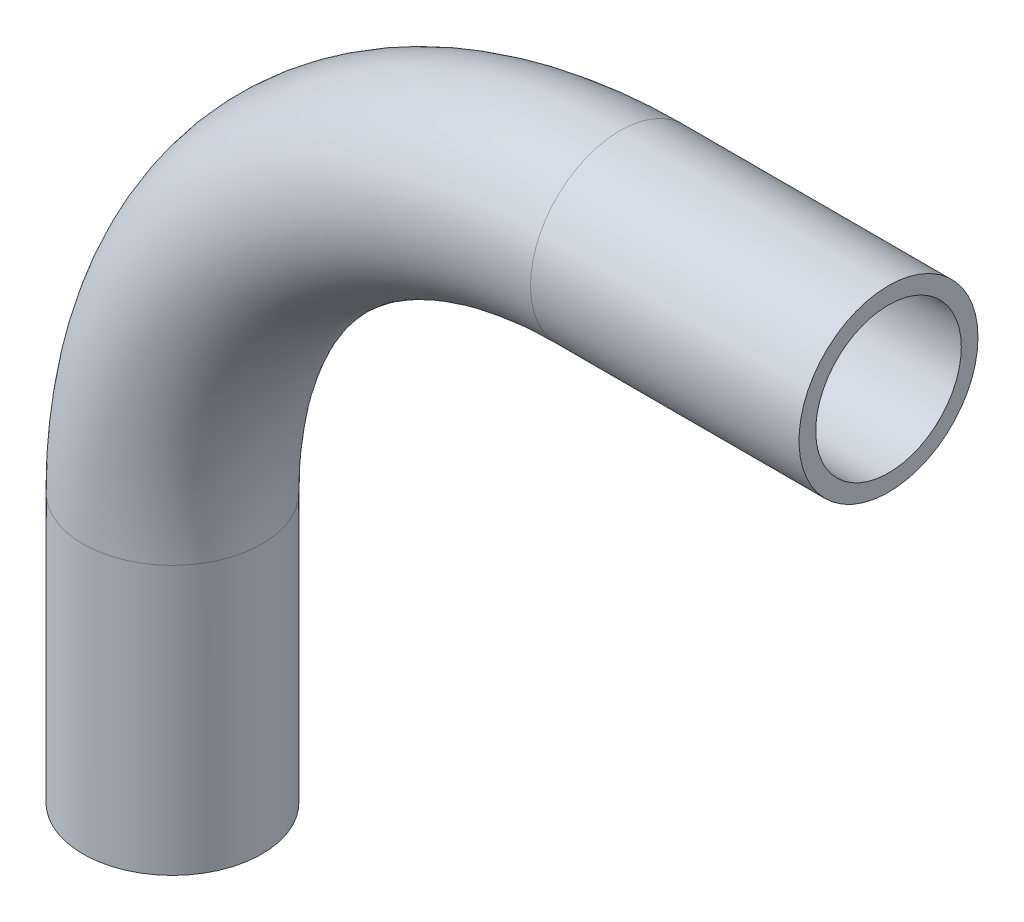
from build123d import *

# Parameters (mm, degrees)
SKETCH2_R   = 4.7625
SKETCH2_R_2 = 3.8735


with BuildPart() as part:
    # Sweep1: sweep along a path in Sketch1
    with BuildLine(Plane.XY) as sweep1_path:
        Line((0, -38.1), (0, -23.8125))
        ThreePointArc((0, -23.8125), (6.974519773, -6.974519773), (23.8125, 0))
        Line((23.8125, 0), (38.1, 0))
    # Sketch2 → Sweep1 (sweep)
    with BuildSketch(Plane(origin=(38.1, 0, 0), x_dir=(0, 0, -1), z_dir=(1, 0, 0))):
        Circle(SKETCH2_R)
        Circle(SKETCH2_R_2, mode=Mode.SUBTRACT)
    sweep(path=sweep1_path.line)


solid = part.part
